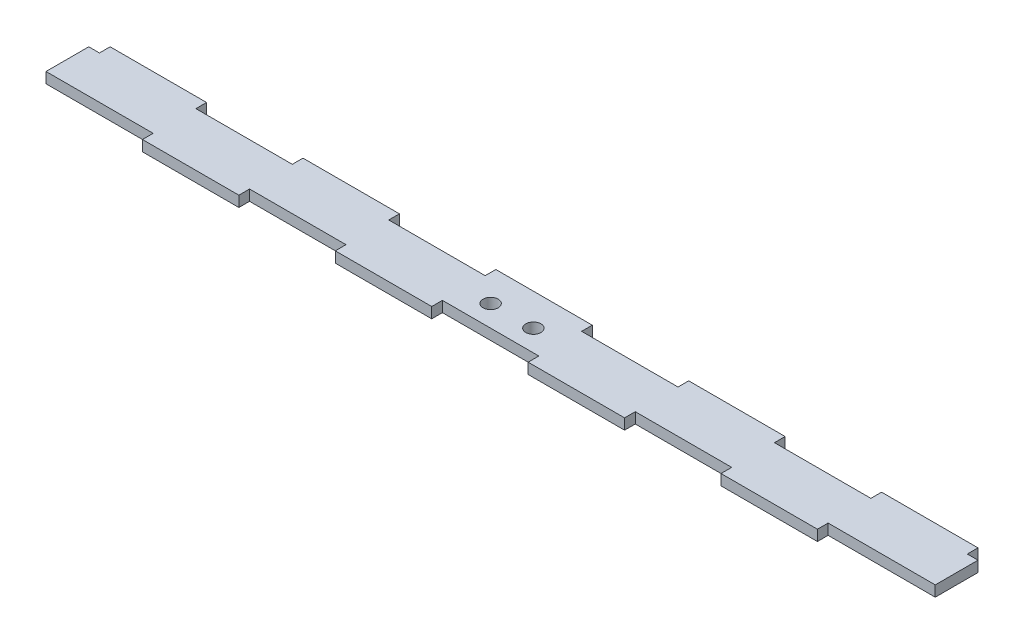
from build123d import *

# Parameters (mm, degrees)
SKETCH1_R           = 2.25
BOSS_EXTRUDE2_DEPTH = 3.175


with BuildPart() as part:
    # Sketch1 → Boss-Extrude2 (new body)
    with BuildSketch(Plane(origin=(0, 0, 0), x_dir=(1, 0, 0), z_dir=(0, 1, 0))):
        Polygon((-128.905, 9.525), (-100.259444444, 9.525), (-100.259444444, 6.35), (-71.613888889, 6.35), (-71.613888889, 9.525), (-42.968333333, 9.525), (-42.968333333, 6.35), (-14.322777778, 6.35), (-14.322777778, 9.525), (14.322777778, 9.525), (14.322777778, 6.35), (42.968333333, 6.35), (42.968333333, 9.525), (71.613888889, 9.525), (71.613888889, 6.35), (100.259444444, 6.35), (100.259444444, 9.525), (128.905, 9.525), (128.905, 6.35), (132.08, 6.35), (132.08, -6.35), (100.259444444, -6.35), (100.259444444, -9.525), (71.613888889, -9.525), (71.613888889, -6.35), (42.968333333, -6.35), (42.968333333, -9.525), (14.322777778, -9.525), (14.322777778, -6.35), (-14.322777778, -6.35), (-14.322777778, -9.525), (-42.968333333, -9.525), (-42.968333333, -6.35), (-71.613888889, -6.35), (-71.613888889, -9.525), (-100.259444444, -9.525), (-100.259444444, -6.35), (-132.08, -6.35), (-132.08, 6.35), (-128.905, 6.35), align=None)
        with Locations((6.35, 0)):
            Circle(SKETCH1_R, mode=Mode.SUBTRACT)
        with Locations((-6.35, 0)):
            Circle(SKETCH1_R, mode=Mode.SUBTRACT)
    extrude(amount=BOSS_EXTRUDE2_DEPTH)


solid = part.part
